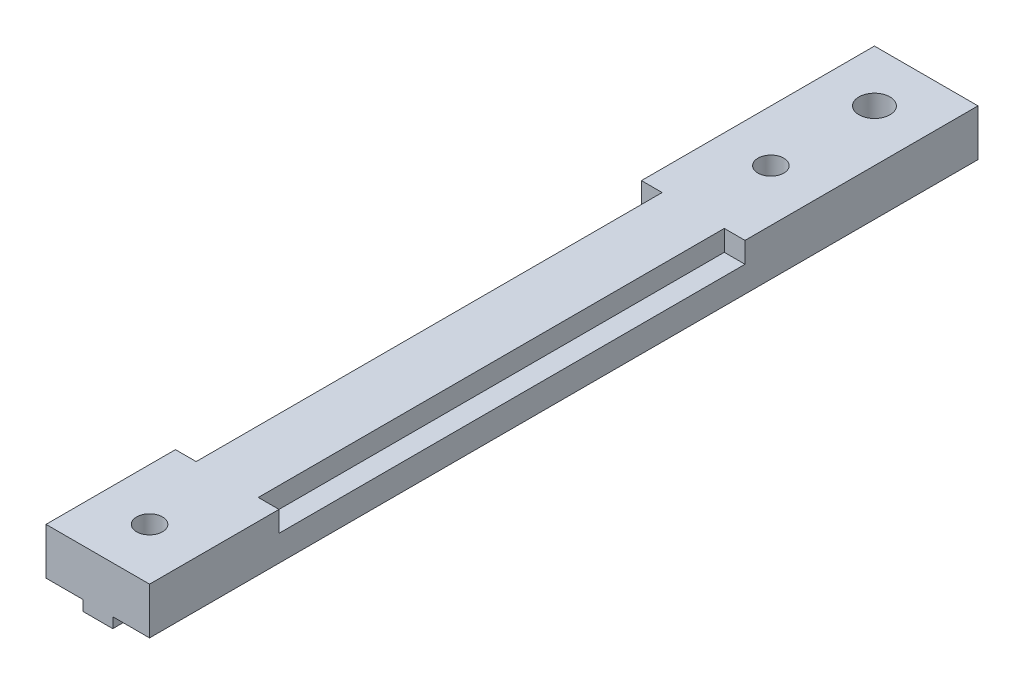
from build123d import *

# Parameters (mm, degrees)
MAIN_DEPTH             = 80
SKETCH2_R              = 1.25
SKETCH2_R_2            = 1.5
MAKERBEAMFIXHOLE_DEPTH = 6.5
SKETCH3_W              = 2
SKETCH3_H              = 45
PINHOLES_DEPTH         = 2


with BuildPart() as part:
    # Sketch1 → Main (new body)
    with BuildSketch(Plane.XY):
        Polygon((-5, 0), (5, 0), (5, -4.5), (1.45, -4.5), (1.45, -5.5), (-1.45, -5.5), (-1.45, -4.5), (-5, -4.5), align=None)
    extrude(amount=MAIN_DEPTH)

    # Sketch2 → MakerBeamFixHole (cut, through all)
    with BuildSketch(Plane(origin=(0, 0, 0), x_dir=(1, 0, 0), z_dir=(0, 1, 0))):
        with Locations((0, -75)):
            Circle(SKETCH2_R)
        with Locations((0, -15)):
            Circle(SKETCH2_R)
        with Locations((0, -5)):
            Circle(SKETCH2_R_2)
    extrude(amount=-MAKERBEAMFIXHOLE_DEPTH, mode=Mode.SUBTRACT)

    # Sketch3 → PinHoles (cut)
    with BuildSketch(Plane(origin=(0, 0, 0), x_dir=(1, 0, 0), z_dir=(0, 1, 0))):
        with Locations((-4, -45)):
            Rectangle(SKETCH3_W, SKETCH3_H)
        with Locations((4, -45)):
            Rectangle(SKETCH3_W, SKETCH3_H)
    extrude(amount=-PINHOLES_DEPTH, mode=Mode.SUBTRACT)


solid = part.part
